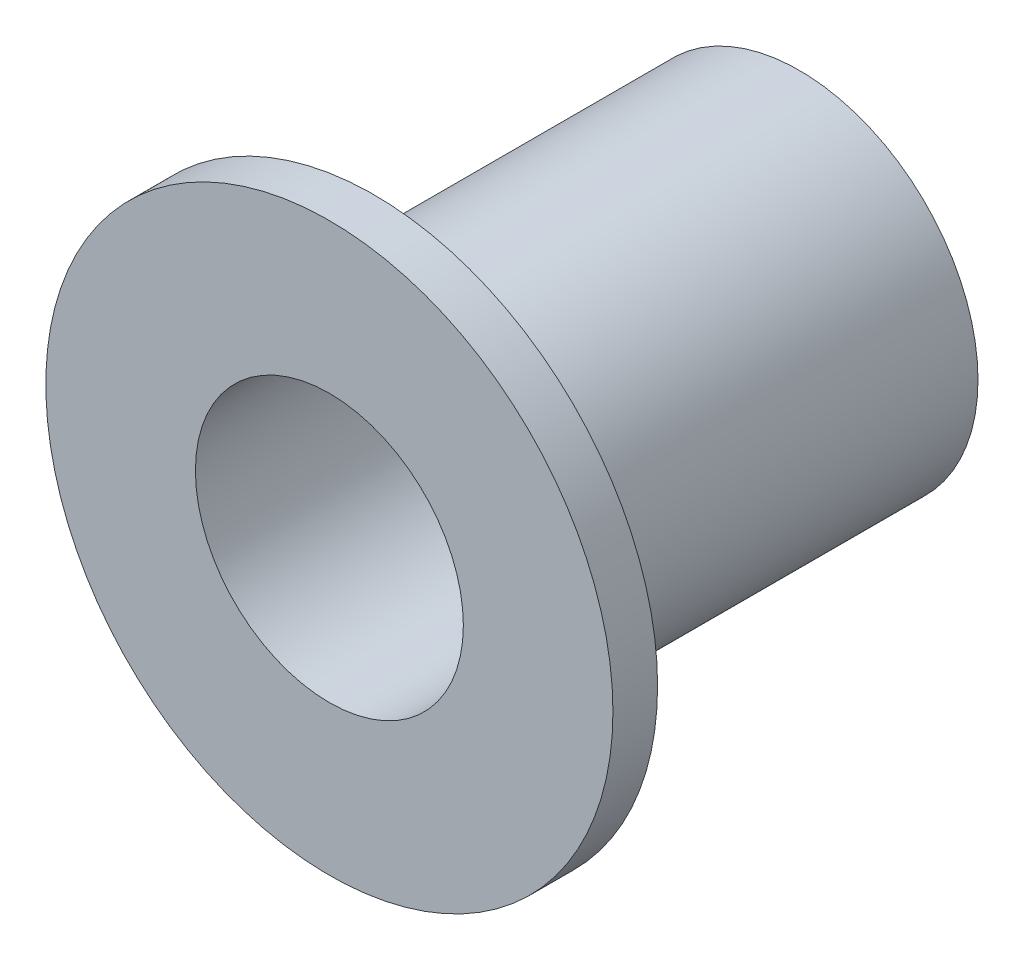
from build123d import *

# Parameters (mm, degrees)
SKETCH1_R           = 6.35
SKETCH1_R_2         = 3
BOSS_EXTRUDE1_DEPTH = 1
SKETCH2_R           = 4
SKETCH2_R_2         = 3
BOSS_EXTRUDE2_DEPTH = 9.525


with BuildPart() as part:
    # Sketch1 → Boss-Extrude1 (new body)
    with BuildSketch(Plane.XY):
        Circle(SKETCH1_R)
        Circle(SKETCH1_R_2, mode=Mode.SUBTRACT)
    extrude(amount=BOSS_EXTRUDE1_DEPTH)

    # Sketch2 → Boss-Extrude2 (add)
    with BuildSketch(Plane(origin=(0, 0, 0), x_dir=(-1, 0, 0), z_dir=(0, 0, -1))):
        Circle(SKETCH2_R)
        Circle(SKETCH2_R_2, mode=Mode.SUBTRACT)
    extrude(amount=BOSS_EXTRUDE2_DEPTH)


solid = part.part
